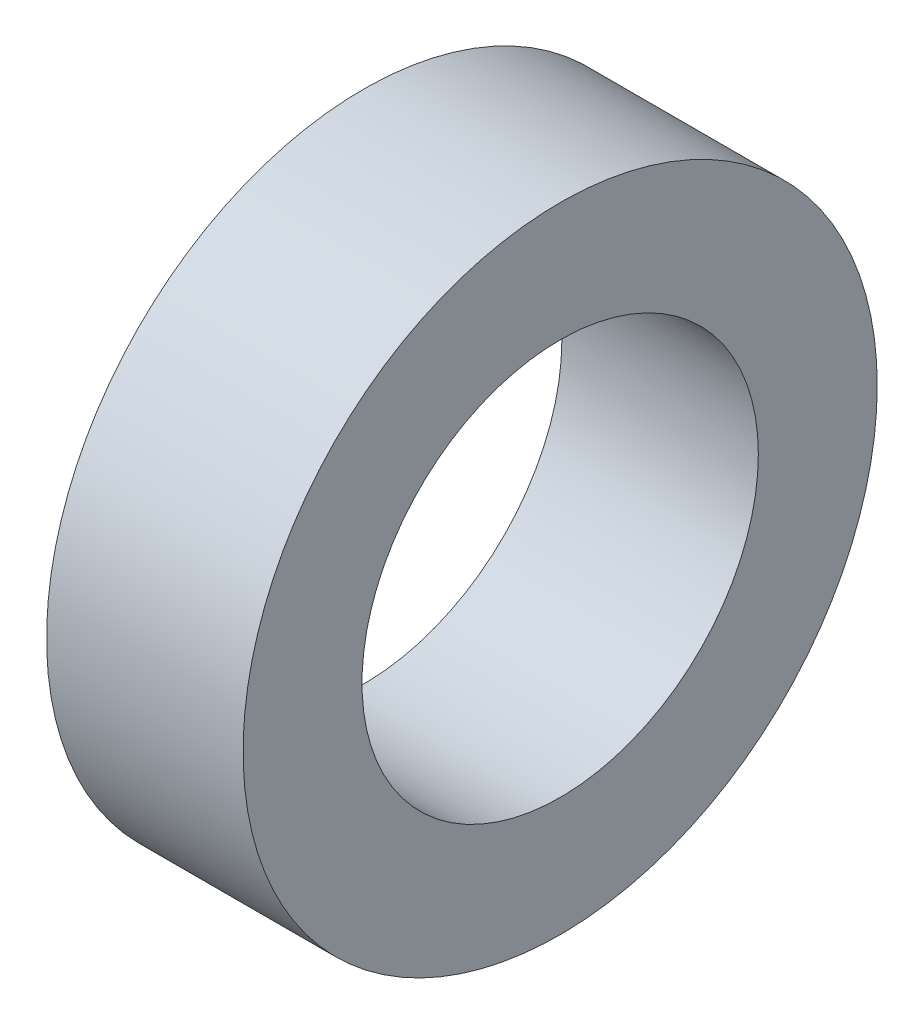
from build123d import *

# Parameters (mm, degrees)
SKETCH1_R           = 10.16
SKETCH1_R_2         = 6.35
BOSS_EXTRUDE1_DEPTH = 6.29666


with BuildPart() as part:
    # Sketch1 → Boss-Extrude1 (new body)
    with BuildSketch(Plane(origin=(0, 0, 0), x_dir=(0, 0, -1), z_dir=(1, 0, 0))):
        Circle(SKETCH1_R)
        Circle(SKETCH1_R_2, mode=Mode.SUBTRACT)
    extrude(amount=BOSS_EXTRUDE1_DEPTH)


solid = part.part
